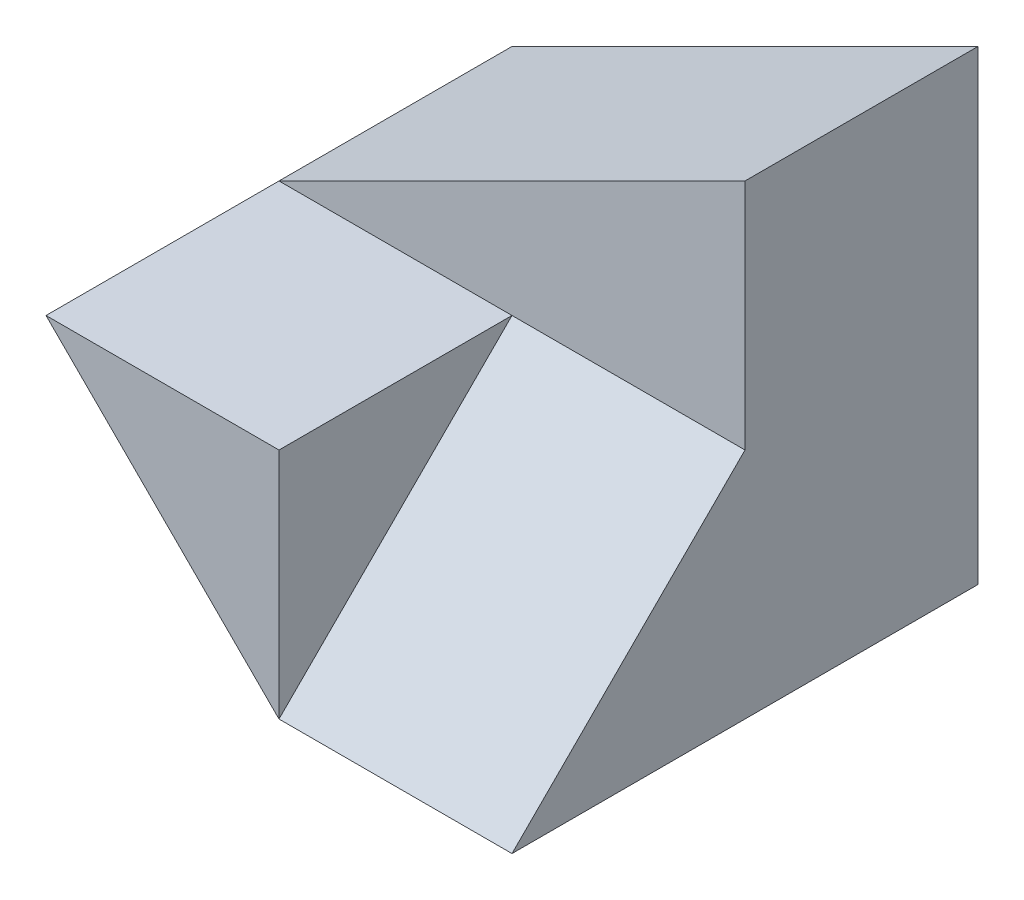
from build123d import *

# Parameters (mm, degrees)
SKETCH1_W           = 40
SKETCH1_H           = 40
BOSS_EXTRUDE1_DEPTH = 40
CUT_EXTRUDE1_DEPTH  = 40
SKETCH3_W           = 20
SKETCH3_H           = 20
CUT_EXTRUDE2_DEPTH  = 40
CUT_EXTRUDE4_DEPTH  = 40
CUT_EXTRUDE5_DEPTH  = 20


with BuildPart() as part:
    # Sketch1 → Boss-Extrude1 (new body)
    with BuildSketch(Plane.XY):
        with Locations((20, 20)):
            Rectangle(SKETCH1_W, SKETCH1_H)
    extrude(amount=BOSS_EXTRUDE1_DEPTH)

    # Sketch2 → Cut-Extrude1 (cut)
    with BuildSketch(Plane.XY.offset(40)):
        Polygon((40, 40), (0, 40), (0, 20), align=None)
    extrude(amount=-CUT_EXTRUDE1_DEPTH, mode=Mode.SUBTRACT)

    # Sketch3 → Cut-Extrude2 (cut)
    with BuildSketch(Plane(origin=(40, 0, 0), x_dir=(0, 0, -1), z_dir=(1, 0, 0))):
        with Locations((-30, 30)):
            Rectangle(SKETCH3_W, SKETCH3_H)
    extrude(amount=-CUT_EXTRUDE2_DEPTH, mode=Mode.SUBTRACT)

    # Sketch4 → Cut-Extrude4 (cut)
    with BuildSketch(Plane.XY.offset(40)):
        Polygon((0, 20), (20, 0), (0, 0), align=None)
    extrude(amount=-CUT_EXTRUDE4_DEPTH, mode=Mode.SUBTRACT)

    # Sketch5 → Cut-Extrude5 (cut)
    with BuildSketch(Plane(origin=(40, 0, 0), x_dir=(0, 0, -1), z_dir=(1, 0, 0))):
        Polygon((-20, 20), (-40, 0), (-40, 20), align=None)
    extrude(amount=-CUT_EXTRUDE5_DEPTH, mode=Mode.SUBTRACT)


solid = part.part
